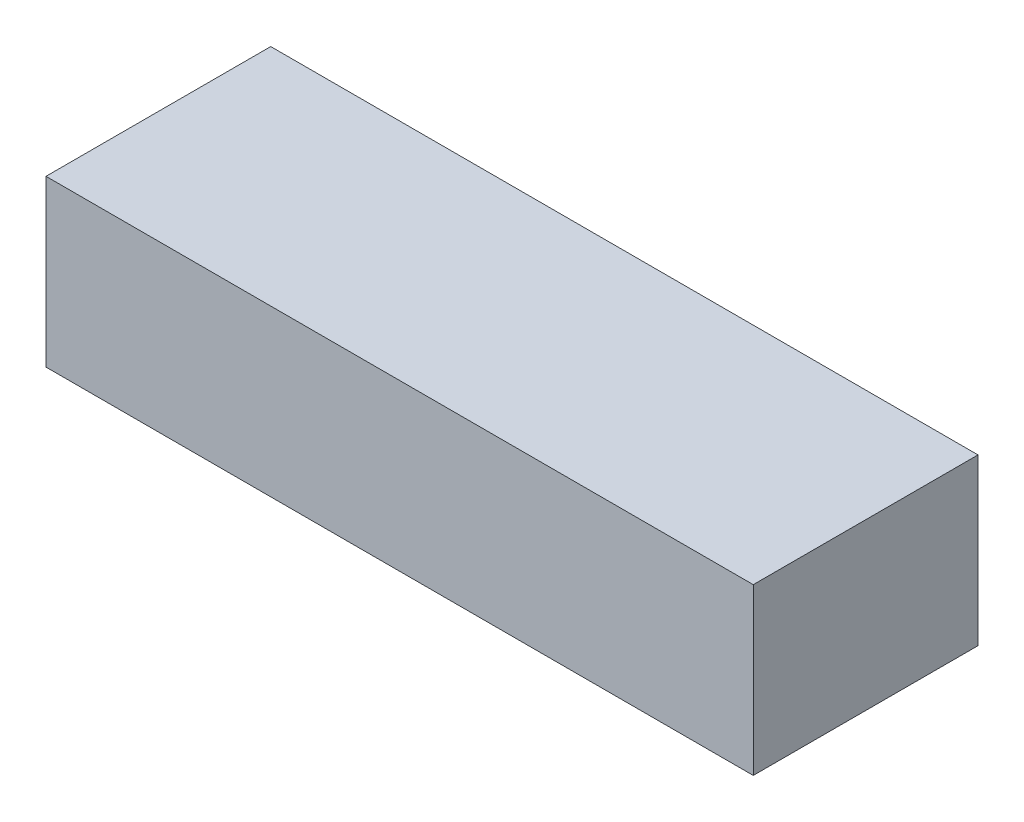
from build123d import *

# Parameters (mm, degrees)
SKETCH1_W           = 107
SKETCH1_H           = 34
BOSS_EXTRUDE1_DEPTH = 25


with BuildPart() as part:
    # Sketch1 → Boss-Extrude1 (new body)
    with BuildSketch(Plane(origin=(0, 0, 0), x_dir=(1, 0, 0), z_dir=(0, 1, 0))):
        Rectangle(SKETCH1_W, SKETCH1_H)
    extrude(amount=BOSS_EXTRUDE1_DEPTH)


solid = part.part
